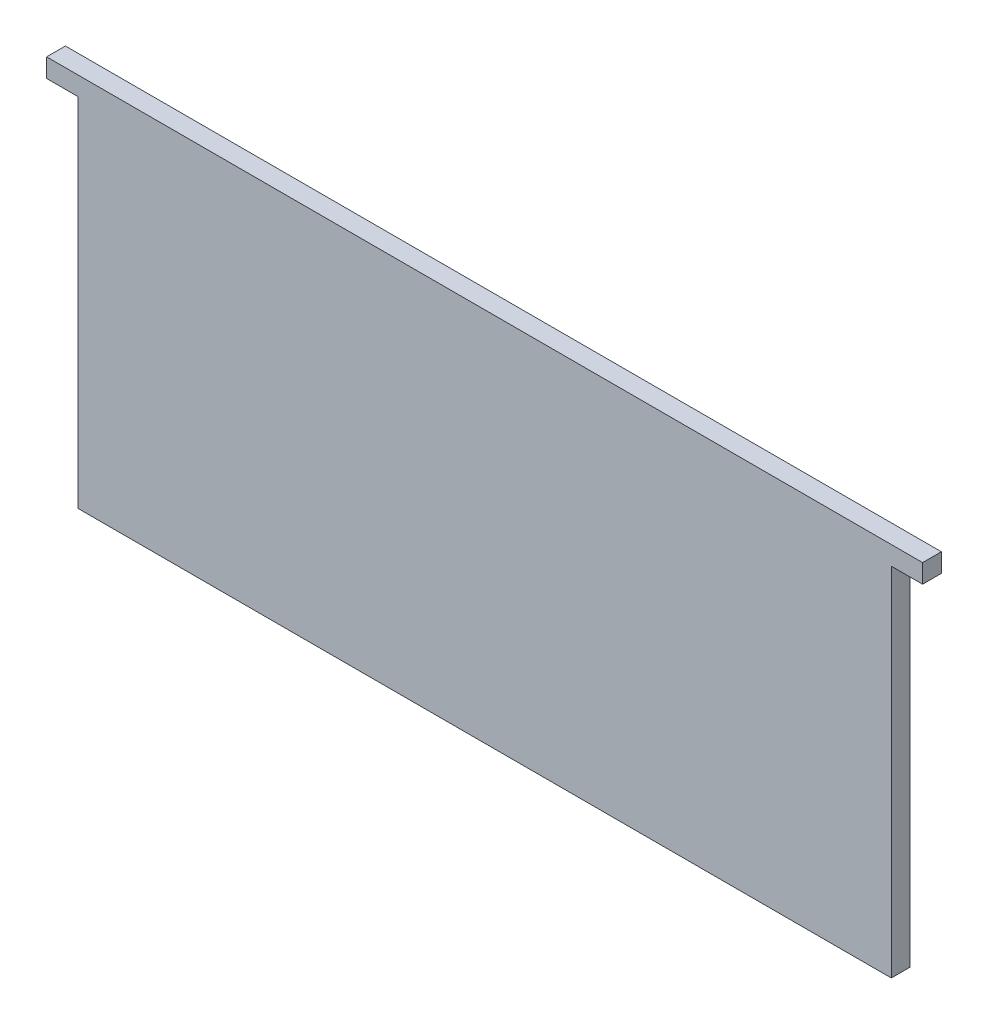
from build123d import *

# Parameters (mm, degrees)
SKETCH2_W           = 130
SKETCH2_H           = 60
SKETCH2_W_2         = 5
SKETCH2_H_2         = 3
BOSS_EXTRUDE1_DEPTH = 3


with BuildPart() as part:
    # Sketch2 → Boss-Extrude1 (new body)
    with BuildSketch(Plane.XY):
        Rectangle(SKETCH2_W, SKETCH2_H)
        with Locations((67.5, 28.5)):
            Rectangle(SKETCH2_W_2, SKETCH2_H_2)
        with Locations((-67.5, 28.5)):
            Rectangle(SKETCH2_W_2, SKETCH2_H_2)
    extrude(amount=BOSS_EXTRUDE1_DEPTH)


solid = part.part
